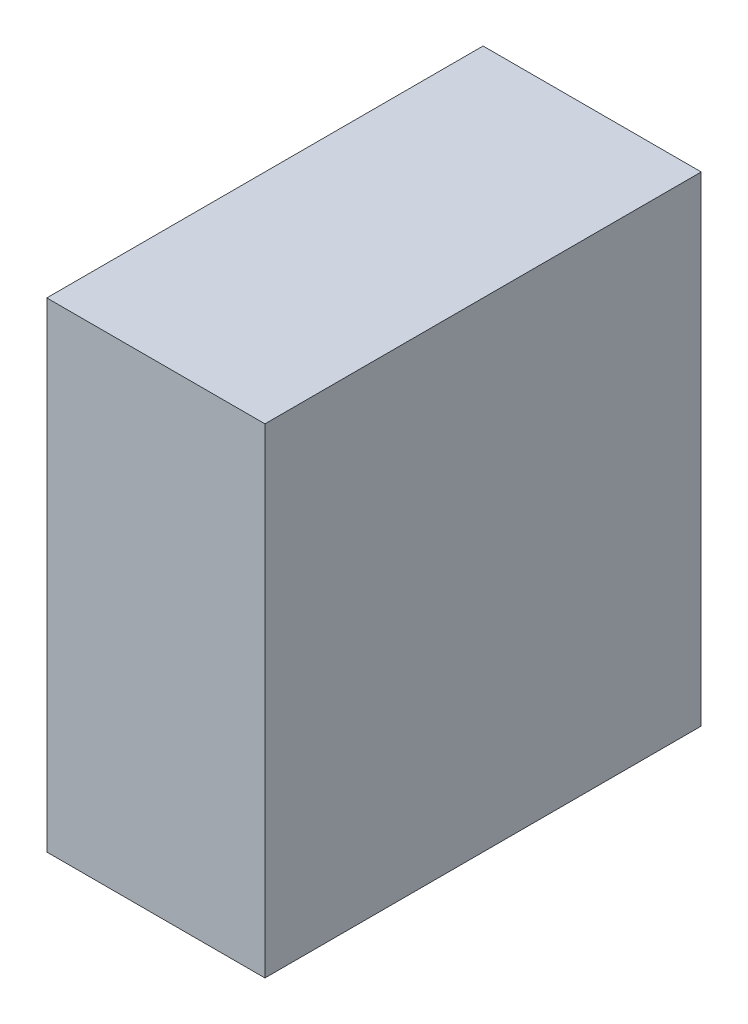
from build123d import *

# Parameters (mm, degrees)
SKETCH1_W           = 5
SKETCH1_H           = 10
BOSS_EXTRUDE1_DEPTH = 11


with BuildPart() as part:
    # Sketch1 → Boss-Extrude1 (new body)
    with BuildSketch(Plane(origin=(0, 0, 0), x_dir=(1, 0, 0), z_dir=(0, 1, 0))):
        with Locations((2.5, -5)):
            Rectangle(SKETCH1_W, SKETCH1_H)
    extrude(amount=BOSS_EXTRUDE1_DEPTH)


solid = part.part
